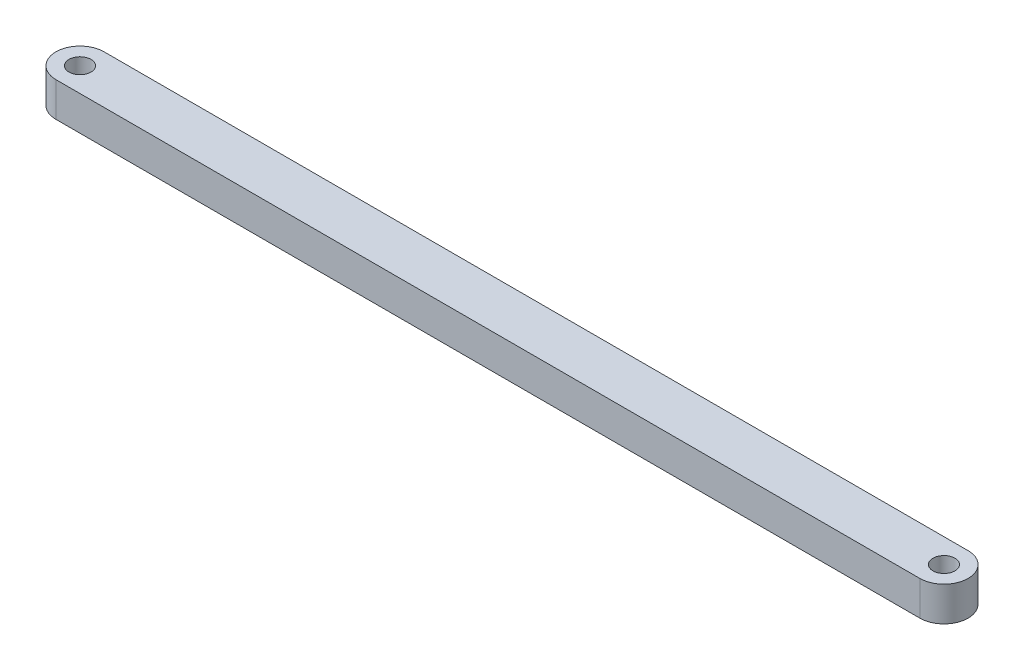
from build123d import *

# Parameters (mm, degrees)
SKETCH1_R           = 1.6
BOSS_EXTRUDE1_DEPTH = 5


with BuildPart() as part:
    # Sketch1 → Boss-Extrude1 (new body)
    with BuildSketch(Plane(origin=(0, 0, 0), x_dir=(1, 0, 0), z_dir=(0, 1, 0))):
        with BuildLine():
            Line((0, 3.5), (125.5, 3.5))
            ThreePointArc((125.5, 3.5), (129, 0), (125.5, -3.5))
            Line((125.5, -3.5), (0, -3.5))
            ThreePointArc((0, -3.5), (-3.5, 0), (0, 3.5))
        make_face()
        Circle(SKETCH1_R, mode=Mode.SUBTRACT)
        with Locations((125.5, 0)):
            Circle(SKETCH1_R, mode=Mode.SUBTRACT)
    extrude(amount=BOSS_EXTRUDE1_DEPTH)


solid = part.part
